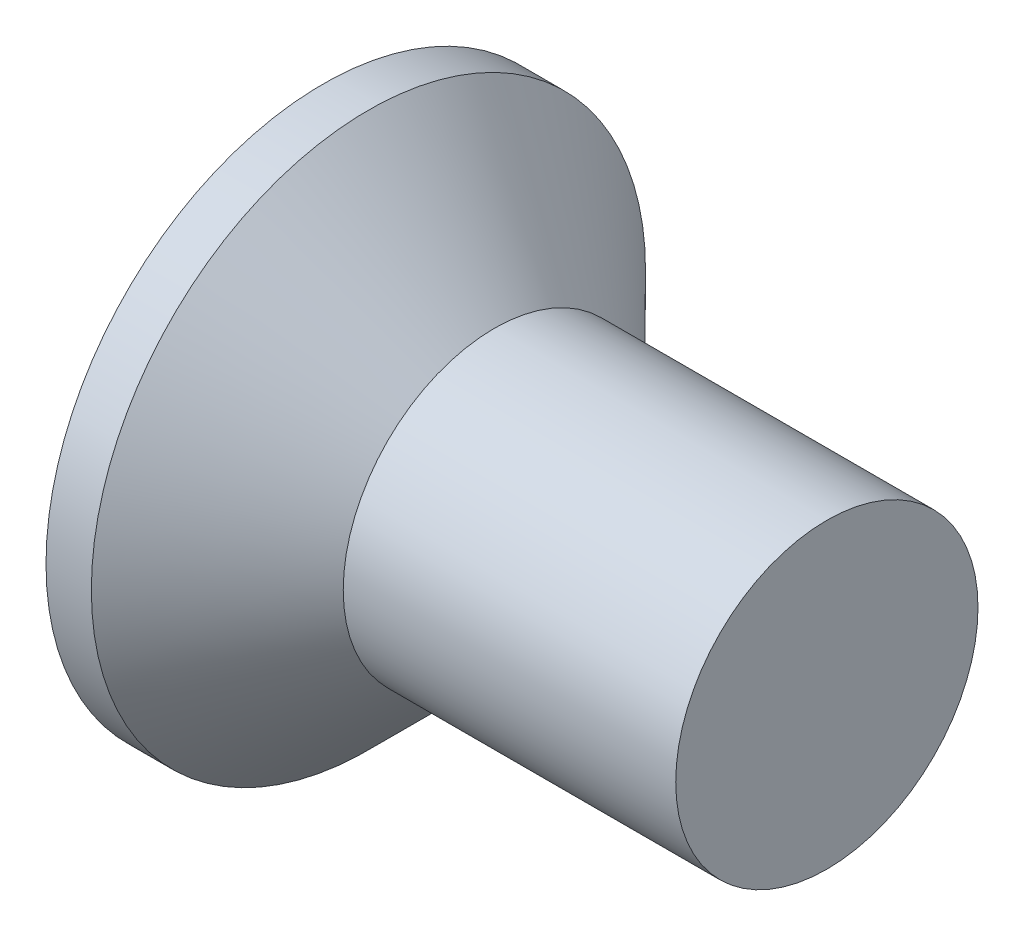
from build123d import *

# Parameters (mm, degrees)
SKETCH3_W         = 0.79
SKETCH3_H         = 3.1
SKETCH4_W         = 0.395
SKETCH4_H         = 0.395
CIRPATTERN1_COUNT = 2
CIRPATTERN1_ANGLE = 90


with BuildPart() as part:
    # BodySke → Base-Revolve (revolve)
    with BuildSketch(Plane.XY, mode=Mode.PRIVATE) as base_revolve_sk:
        Polygon((0, 0), (0, 2.75), (0.45, 2.75), (1.7, 1.5), (5, 1.5), (5, 0), align=None)
    revolve(base_revolve_sk.sketch.rotate(Axis((-6.35, 0, 0), (1, 0, 0)), 90), axis=Axis((-6.35, 0, 0), (1, 0, 0)))  # turned: the seam where the file's is

    # Sketch3 → Cross section 0
    with BuildSketch(Plane.ZY):
        Rectangle(SKETCH3_W, SKETCH3_H)
    # Sketch4 → Cross section 1
    with BuildSketch(Plane.ZY.offset(-2.08)):
        Rectangle(SKETCH4_W, SKETCH4_H)
    cross = loft(mode=Mode.SUBTRACT)

    # CirPattern1: Cross ×2 about axis
    cirpattern1_axis = Axis((0, 0, 0), (1, 0, 0))
    for i in range(1, CIRPATTERN1_COUNT):
        add(cross.rotate(cirpattern1_axis, i * CIRPATTERN1_ANGLE / (CIRPATTERN1_COUNT - 1)), mode=Mode.SUBTRACT)


solid = part.part
